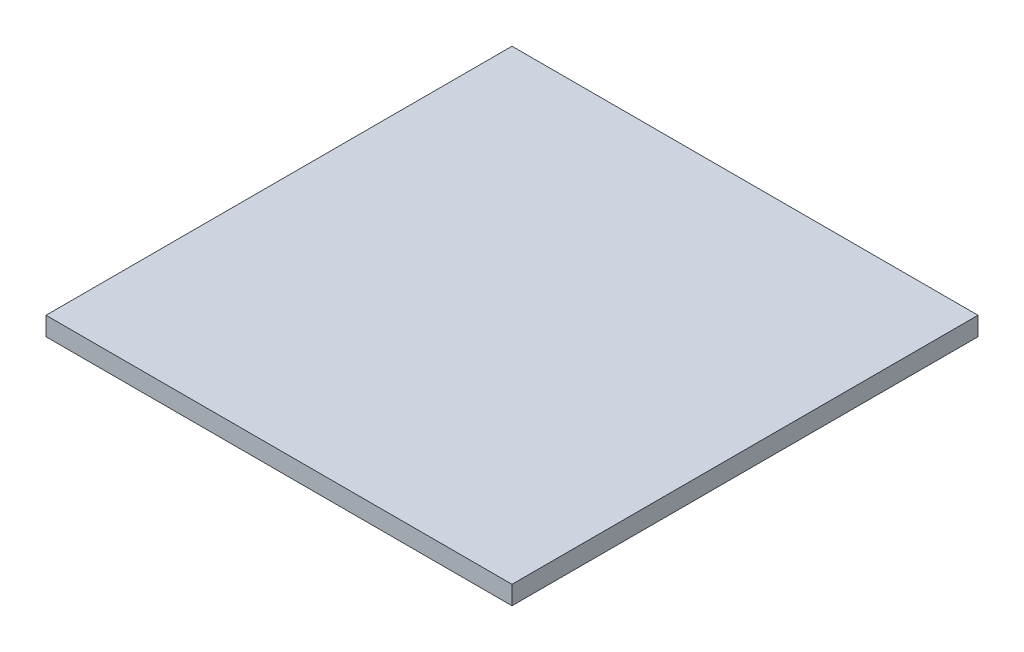
from build123d import *

# Parameters (mm, degrees)
SKETCH2_W           = 25
SKETCH2_H           = 25
BOSS_EXTRUDE1_DEPTH = 1


with BuildPart() as part:
    # Sketch2 → Boss-Extrude1 (new body)
    with BuildSketch(Plane(origin=(0, 0, 0), x_dir=(1, 0, 0), z_dir=(0, 1, 0))):
        with Locations((-8.410037454, 3.731881862)):
            Rectangle(SKETCH2_W, SKETCH2_H)
    extrude(amount=BOSS_EXTRUDE1_DEPTH)


solid = part.part
